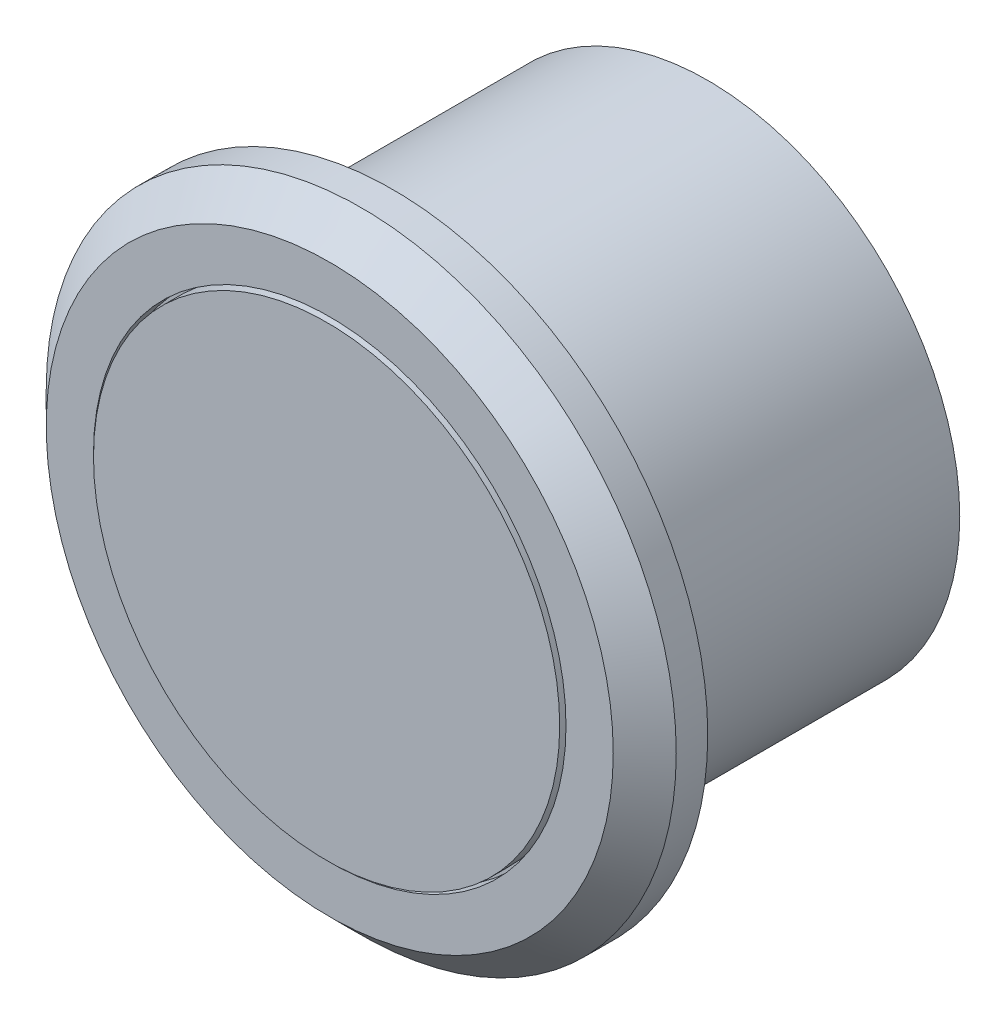
from build123d import *

# Parameters (mm, degrees)
ESQUISSE1_R             = 8
BOSS_EXTRU_1_DEPTH      = 10
ESQUISSE2_R             = 10
BOSS_EXTRU_2_DEPTH      = 2
CHANFREIN1_SIZE         = 1
ESQUISSE3_R             = 7.5
ENL_V_MAT_EXTRU_1_DEPTH = 0.5
ESQUISSE4_R             = 7.4
BOSS_EXTRU_3_DEPTH      = 0.6


with BuildPart() as part:
    # Esquisse1 → Boss.-Extru.1 (new body)
    with BuildSketch(Plane.XY):
        Circle(ESQUISSE1_R)
    extrude(amount=BOSS_EXTRU_1_DEPTH)

    # Esquisse2 → Boss.-Extru.2 (add)
    with BuildSketch(Plane.XY.offset(10)):
        Circle(ESQUISSE2_R)
    extrude(amount=BOSS_EXTRU_2_DEPTH)

    # Chanfrein1
    chanfrein1_edges = [part.edges().sort_by_distance(p)[0] for p in [
        (-10, 0, 12),
    ]]
    chamfer(chanfrein1_edges, length=CHANFREIN1_SIZE)

    # Esquisse3 → Enlèv. mat.-Extru.1 (cut)
    with BuildSketch(Plane.XY.offset(12)):
        Circle(ESQUISSE3_R)
    extrude(amount=-ENL_V_MAT_EXTRU_1_DEPTH, mode=Mode.SUBTRACT)

    # Esquisse4 → Boss.-Extru.3 (add)
    with BuildSketch(Plane.XY.offset(11.5)):
        Circle(ESQUISSE4_R)
    extrude(amount=BOSS_EXTRU_3_DEPTH)


solid = part.part
